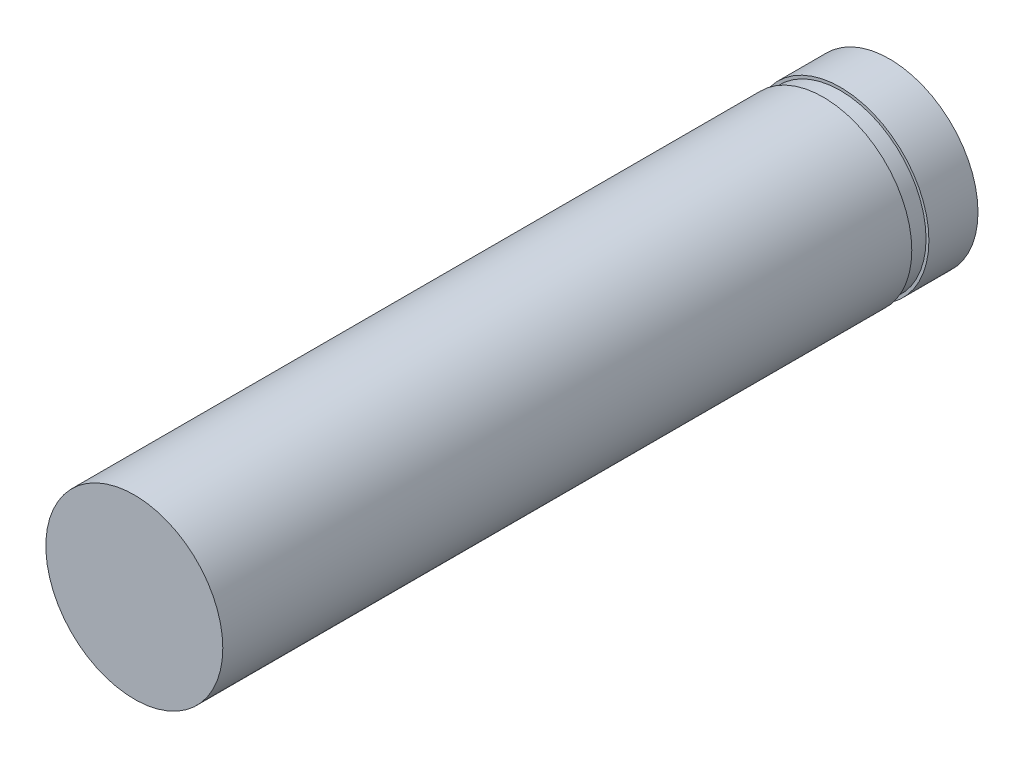
from build123d import *

# Parameters (mm, degrees)
ESQUISSE1_R      = 1.55
EXTRUSION1_DEPTH = 13.23
ESQUISSE2_W      = 0.05
ESQUISSE2_H      = 0.3


with BuildPart() as part:
    # Esquisse1 → Extrusion1 (new body)
    with BuildSketch(Plane.XY):
        Circle(ESQUISSE1_R)
    extrude(amount=-EXTRUSION1_DEPTH)

    # Esquisse2 → Enlèvement de matière-Révolution1 (revolve, cut)
    with BuildSketch(Plane(origin=(0, 0, 0), x_dir=(1, 0, 0), z_dir=(0, 1, 0))):
        with Locations((1.525, 12.22)):
            Rectangle(ESQUISSE2_W, ESQUISSE2_H)
    revolve(axis=Axis((0, 0, 0.313071183), (0, 0, -1)), mode=Mode.SUBTRACT)


solid = part.part
